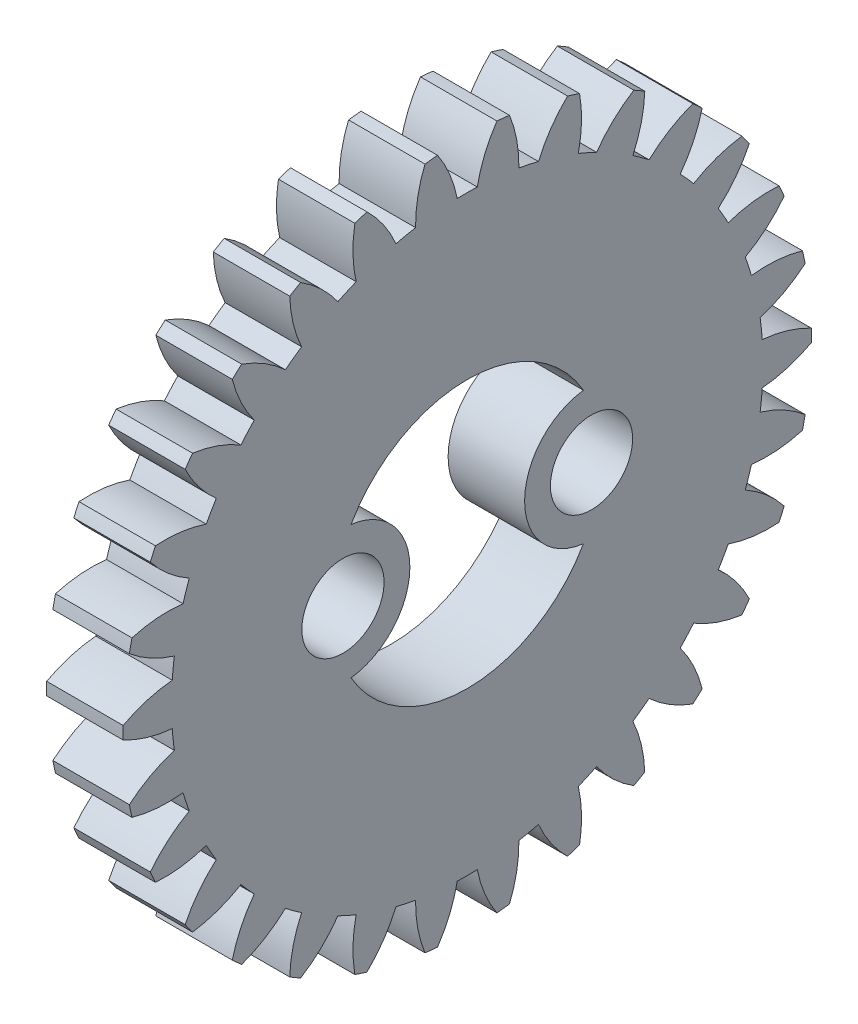
from build123d import *

# Parameters (mm, degrees)
BASPROSKE_W          = 4
BASPROSKE_H          = 18
TOOTHCUT_DEPTH       = 26.768197453
TEETHCUTS_COUNT      = 30
TEETHCUTS_ANGLE      = 348
BORSKE_R             = 7
BORE_DEPTH           = 50.0000508
SKETCH2_R            = 3.5
BOSS_EXTRUDE1_DEPTH  = 4
M4_CLEARANCE_HOLE1_D = 4.3


with BuildPart() as part:
    # BasProSke → Base-Revolve (revolve)
    with BuildSketch(Plane(origin=(0, 0, 0), x_dir=(1, 0, 0), z_dir=(0, 1, 0)), mode=Mode.PRIVATE) as base_revolve_sk:
        with Locations((2, 9)):
            Rectangle(BASPROSKE_W, BASPROSKE_H)
    revolve(base_revolve_sk.sketch.rotate(Axis((-10, 0, 0), (1, 0, 0)), 180), axis=Axis((-10, 0, 0), (1, 0, 0)))

    # TooCutSke → ToothCut (cut, through all)
    with BuildSketch(Plane(origin=(0, 0, 0), x_dir=(0, 0, -1), z_dir=(1, 0, 0))):
        with BuildLine():
            ThreePointArc((0.523521522, 15.458887906), (0, 15.46775), (-0.523521522, 15.458887906))
            ThreePointArc((-0.523521522, 15.458887906), (-0.919551256, 16.760900189), (-1.568701479, 17.957010353))
            ThreePointArc((-1.568701479, 17.957010353), (0, 18.0254), (1.568701479, 17.957010353))
            ThreePointArc((1.568701479, 17.957010353), (0.919551256, 16.760900189), (0.523521522, 15.458887906))
        make_face()
    toothcut = extrude(amount=TOOTHCUT_DEPTH, mode=Mode.SUBTRACT)

    # TeethCuts: ToothCut ×30 about axis
    teethcuts_axis = Axis((-10, 0, 0), (1, 0, 0))
    for i in range(1, TEETHCUTS_COUNT):
        add(toothcut.rotate(teethcuts_axis, i * TEETHCUTS_ANGLE / (TEETHCUTS_COUNT - 1)), mode=Mode.SUBTRACT)

    # BorSke → Bore (cut, symmetric)
    with BuildSketch(Plane(origin=(0, 0, 0), x_dir=(0, 0, -1), z_dir=(1, 0, 0))):
        with Locations(Location((0, 0, 0), (0, 0, 180))):
            Circle(BORSKE_R)
    extrude(amount=BORE_DEPTH, both=True, mode=Mode.SUBTRACT)

    # Sketch2 → Boss-Extrude1 (add)
    with BuildSketch(Plane.ZY):
        with Locations((-6.5, 0)):
            Circle(SKETCH2_R)
        with Locations((6.5, 0)):
            Circle(SKETCH2_R)
    extrude(amount=-BOSS_EXTRUDE1_DEPTH)

    # M4 Clearance Hole1 (through all)
    with Locations(Plane.ZY):
        with Locations((-6.5, 0), (6.5, 0)):
            Hole(M4_CLEARANCE_HOLE1_D / 2)


solid = part.part
